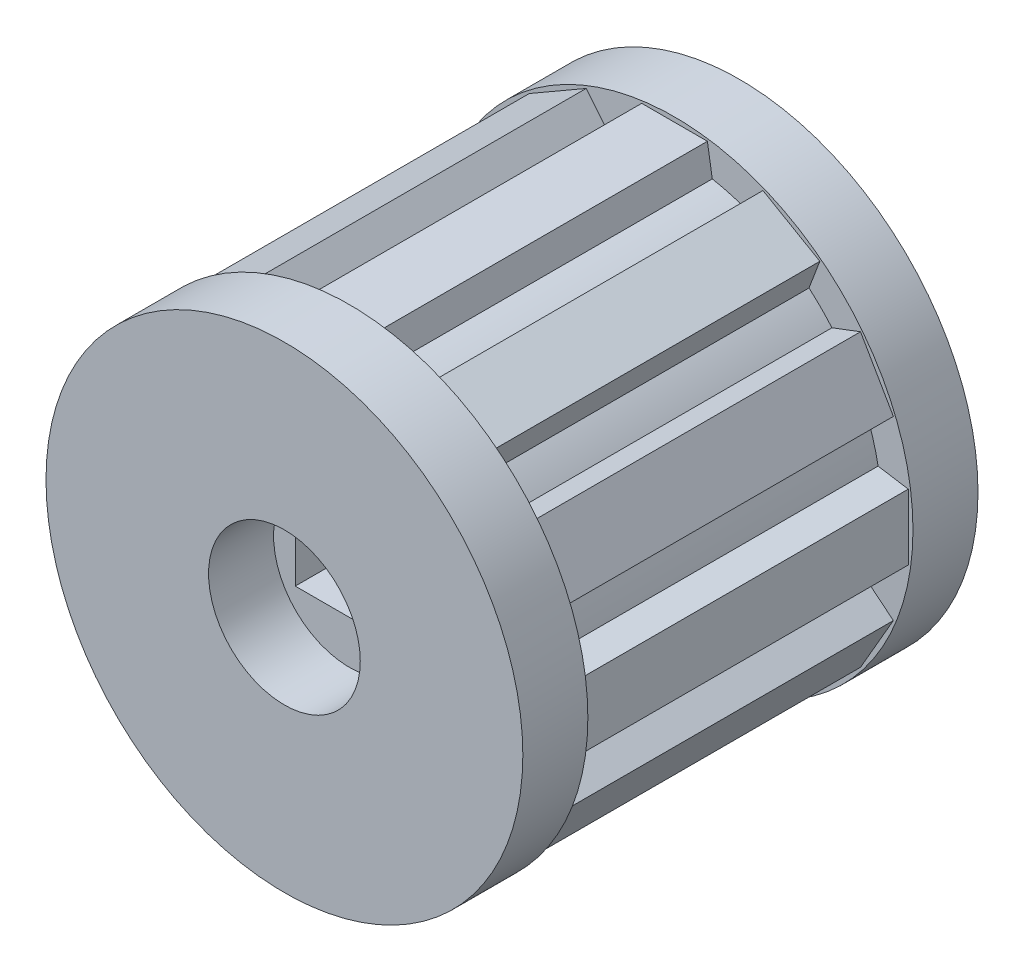
from build123d import *

# Parameters (mm, degrees)
ESQUISSE1_R                  = 11
ESQUISSE1_R_2                = 3.5
BOSS_EXTRU_1_DEPTH           = 21
ESQUISSE3_R                  = 28.5
ESQUISSE3_R_2                = 9.55
ENL_V_MAT_EXTRU_1_DEPTH      = 15
BOSS_EXTRU_2_DEPTH           = 15
R_P_TITION_CIRCULAIRE1_COUNT = 12
BOSS_EXTRUDE1_START          = 10.5
ESQUISSE1_3_R                = 3.5
ESQUISSE1_3_W                = 5
ESQUISSE1_3_H                = 3
BOSS_EXTRUDE1_DEPTH          = 7.5


with BuildPart() as part:
    # Esquisse1 → Boss.-Extru.1 (new body)
    with BuildSketch(Plane.XY):
        Circle(ESQUISSE1_R)
        Circle(ESQUISSE1_R_2, mode=Mode.SUBTRACT)
    extrude(amount=BOSS_EXTRU_1_DEPTH)

    # Esquisse3 → Enlèv. mat.-Extru.1 (cut)
    with BuildSketch(Plane(origin=(0, 0, 3), x_dir=(-1, 0, 0), z_dir=(0, 0, -1))):
        Circle(ESQUISSE3_R)
        Circle(ESQUISSE3_R_2, mode=Mode.SUBTRACT)
    extrude(amount=-ENL_V_MAT_EXTRU_1_DEPTH, mode=Mode.SUBTRACT)

    # Esquisse5 → Boss.-Extru.2 (add)
    with BuildSketch(Plane.XY.offset(3)):
        with BuildLine():
            Line((-1.740349268, 9.390084367), (-1.515334698, 10.782166631))
            Line((-1.515334698, 10.782166631), (1.515334698, 10.782166631))
            Line((1.515334698, 10.782166631), (1.740349268, 9.390084367))
            ThreePointArc((1.740349268, 9.390084367), (0, 9.55), (-1.740349268, 9.390084367))
        make_face()
    boss_extru_2 = extrude(amount=BOSS_EXTRU_2_DEPTH)

    # Répétition circulaire1: Boss.-Extru.2 ×12 about axis
    r_p_tition_circulaire1_axis = Axis((0, 0, 0), (0, 0, 1))
    for i in range(1, R_P_TITION_CIRCULAIRE1_COUNT):
        add(boss_extru_2.rotate(r_p_tition_circulaire1_axis, i * 360 / R_P_TITION_CIRCULAIRE1_COUNT))

    # Esquisse1_3 → Boss-Extrude1 (add, symmetric)
    with BuildSketch(Plane.XY.offset(BOSS_EXTRUDE1_START)):
        Circle(ESQUISSE1_3_R)
        Rectangle(ESQUISSE1_3_W, ESQUISSE1_3_H, mode=Mode.SUBTRACT)
    extrude(amount=BOSS_EXTRUDE1_DEPTH, both=True)


solid = part.part
